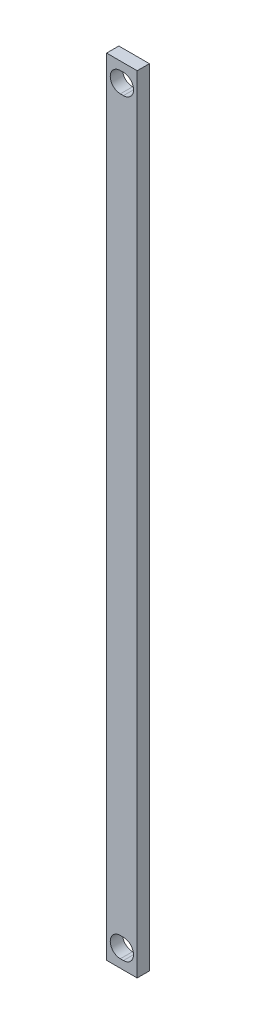
from build123d import *

# Parameters (mm, degrees)
SKETCH1_W           = 5
SKETCH1_H           = 128.5
BOSS_EXTRUDE1_DEPTH = 2


with BuildPart() as part:
    # Sketch1 → Boss-Extrude1 (new body)
    with BuildSketch(Plane.XY):
        Rectangle(SKETCH1_W, SKETCH1_H)
        with BuildLine():
            Line((-0.254, -59.6), (0.254, -59.6))
            ThreePointArc((0.254, -59.6), (1.904, -61.25), (0.254, -62.9))
            Line((0.254, -62.9), (-0.254, -62.9))
            ThreePointArc((-0.254, -62.9), (-1.904, -61.25), (-0.254, -59.6))
        make_face(mode=Mode.SUBTRACT)
        with BuildLine():
            Line((-0.254, 62.9), (0.254, 62.9))
            ThreePointArc((0.254, 62.9), (1.904, 61.25), (0.254, 59.6))
            Line((0.254, 59.6), (-0.254, 59.6))
            ThreePointArc((-0.254, 59.6), (-1.904, 61.25), (-0.254, 62.9))
        make_face(mode=Mode.SUBTRACT)
    extrude(amount=BOSS_EXTRUDE1_DEPTH)


solid = part.part
